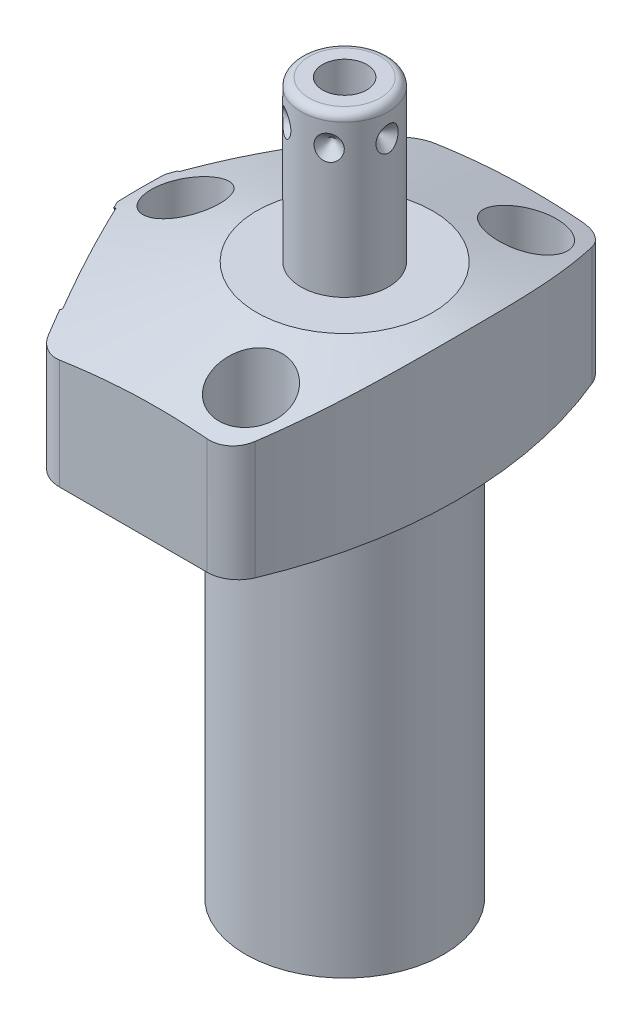
from build123d import *

# Parameters (mm, degrees)
CUT_EXTRUDE1_REACH = 21.05
CUT_EXTRUDE2_REACH = 21.05
S2D0002_OUTSIDE_W  = 78.27
S2D0002_OUTSIDE_H  = 69.906
CUT_EXTRUDE3_DEPTH = 26.035
FILLET1_R          = 3.9624
SKETCH17_R         = 10.4775
CUT_EXTRUDE4_DEPTH = 0.254
SKETCH18_R         = 10.4775
CUT_EXTRUDE5_DEPTH = 0.254
SKETCH19_R         = 5.5626
CUT_EXTRUDE6_DEPTH = 2.667
SKETCH12_R         = 4.8006
EXTRUDE1_DEPTH     = 1.651
EXTRUDE2_START     = -2.667
SKETCH13_R         = 4.8006
EXTRUDE2_DEPTH     = 2.667
CIRPATTERN1_COUNT  = 6
HOLE1_D            = 5.5626
HOLE1_DEPTH        = 19.05
HOLE1_CBORE_D      = 8.7122
HOLE1_CBORE_DEPTH  = 11.0998


with BuildPart() as part:
    # Sketch1 → Revolve1 (revolve)
    with BuildSketch(Plane(origin=(0, 0, 0), x_dir=(0, -1, 0), z_dir=(0, 0, 1)), mode=Mode.PRIVATE) as revolve1_sk:
        Polygon((0, 28.575), (-19.05, 28.575), (-19.05, 0), (50.8, 0), (50.8, 12.573), (0, 12.573), align=None)
    revolve(revolve1_sk.sketch.rotate(Axis((0, 22.5425, 0), (0, -1, 0)), 90), axis=Axis((0, 22.5425, 0), (0, -1, 0)))  # turned: the seam where the file's is

    # Sketch2 → Cut-Extrude1 (cut, up to next)
    with BuildSketch(Plane(origin=(0, 0, 0), x_dir=(0, 0, -1), z_dir=(0, -1, 0)), mode=Mode.PRIVATE) as cut_extrude1_sk1:
        with BuildLine():
            Line((23.8125, -15.795425564), (23.8125, 15.795425564))
            ThreePointArc((23.8125, 15.795425564), (28.575, 0), (23.8125, -15.795425564))
        make_face()
    cut_extrude1_tool1 = extrude(cut_extrude1_sk1.sketch, amount=-CUT_EXTRUDE1_REACH, mode=Mode.PRIVATE) & part.part
    add(cut_extrude1_tool1.solids().sort_by_distance((0, 0, -25.731798))[0], mode=Mode.SUBTRACT)
    # Sketch2 → Cut-Extrude1 (cut, up to next)
    with BuildSketch(Plane(origin=(0, 0, 0), x_dir=(0, 0, -1), z_dir=(0, -1, 0)), mode=Mode.PRIVATE) as cut_extrude1_sk2:
        with BuildLine():
            Line((-23.8125, 15.795425564), (-23.8125, -15.795425564))
            ThreePointArc((-23.8125, -15.795425564), (-28.575, 0), (-23.8125, 15.795425564))
        make_face()
    cut_extrude1_tool2 = extrude(cut_extrude1_sk2.sketch, amount=-CUT_EXTRUDE1_REACH, mode=Mode.PRIVATE) & part.part
    add(cut_extrude1_tool2.solids().sort_by_distance((0, 0, 25.731798))[0], mode=Mode.SUBTRACT)

    # Sketch3 → Cut-Extrude2 (cut, up to next)
    with BuildSketch(Plane(origin=(0, 0, 0), x_dir=(-1, 0, 0), z_dir=(0, -1, 0)), mode=Mode.PRIVATE) as cut_extrude2_sk1:
        with BuildLine():
            Line((14.75388632, 23.8125), (27.415217161, 0))
            Line((27.415217161, 0), (14.75388632, -23.8125))
            Line((14.75388632, -23.8125), (15.795425564, -23.8125))
            ThreePointArc((15.795425564, -23.8125), (28.575, 0), (15.795425564, 23.8125))
            Line((15.795425564, 23.8125), (14.75388632, 23.8125))
        make_face()
    cut_extrude2_tool1 = extrude(cut_extrude2_sk1.sketch, amount=-CUT_EXTRUDE2_REACH, mode=Mode.PRIVATE) & part.part
    add(cut_extrude2_tool1.solids().sort_by_distance((-15.274656, 0, -23.3166))[0], mode=Mode.SUBTRACT)

    # S2D0002 outside → Cut-Extrude3 (cut)
    with BuildSketch(Plane(origin=(0, 0, 0), x_dir=(-1, 0, 0), z_dir=(0, -1, 0))):
        with Locations((-0.58, 0)):
            Rectangle(S2D0002_OUTSIDE_W, S2D0002_OUTSIDE_H)
        with BuildLine():
            Line((25.8064, 53.379071452), (25.8064, -53.379071452))
            ThreePointArc((25.8064, -53.379071452), (-14.3002, 0), (25.8064, 53.379071452))
        make_face(mode=Mode.SUBTRACT)
    extrude(amount=-CUT_EXTRUDE3_DEPTH, mode=Mode.SUBTRACT)

    # Fillet1
    fillet1_edges = [part.edges().sort_by_distance(p)[0] for p in [
        (-14.75388632, 9.525, 23.8125),
        (-14.75388632, 9.525, -23.8125),
        (8.940213818, 9.525, 23.8125),
        (8.940213818, 9.525, -23.8125),
    ]]
    fillet(fillet1_edges, radius=FILLET1_R)

    # Sketch5 → Cut-Revolve1 (revolve, cut)
    with BuildSketch(Plane.XY, mode=Mode.PRIVATE) as cut_revolve1_sk:
        Polygon((-11.176, 19.05), (-44.45, 8.238622028), (-44.45, 19.05), align=None)
    revolve(cut_revolve1_sk.sketch.rotate(Axis((0, 5.998428823, 0), (0, 1, 0)), 90), axis=Axis((0, 5.998428823, 0), (0, 1, 0)), mode=Mode.SUBTRACT)  # turned: the seam where the file's is

    # Sketch6 → Cut-Revolve2 (revolve, cut)
    with BuildSketch(Plane(origin=(-21.148537334, 7.9502, -11.244876766), x_dir=(0.469471563, 0, -0.882947593), z_dir=(0, 1, 0))):
        Polygon((0, 0), (4.5466, 0), (4.106586662, -2.0701), (3.4544, -2.722286662), (3.4544, -12.192), (0, -12.192), align=None)
    revolve(axis=Axis((-9.845395429, 7.9502, -5.234889608), (-0.882947593, 0, -0.469471563)), mode=Mode.SUBTRACT)

    # Sketch7 → Cut-Revolve3 (revolve, cut)
    with BuildSketch(Plane(origin=(-21.148537334, 7.9502, 11.244876766), x_dir=(-0.469471563, 0, -0.882947593), z_dir=(0, 1, 0))):
        Polygon((0, 0), (4.5466, 0), (4.106586662, -2.0701), (3.4544, -2.722286662), (3.4544, -12.192), (0, -12.192), align=None)
    revolve(axis=Axis((-9.845395429, 7.9502, 5.234889608), (-0.882947593, 0, 0.469471563)), mode=Mode.SUBTRACT)

    # Sketch17 → Cut-Extrude4 (cut)
    with BuildSketch(Plane(origin=(-21.372806022, 0, 11.364122543), x_dir=(0.469471563, 0, 0.882947593), z_dir=(-0.882947593, 0, 0.469471563))):
        with Locations((0, 7.9502)):
            Circle(SKETCH17_R)
    extrude(amount=-CUT_EXTRUDE4_DEPTH, mode=Mode.SUBTRACT)

    # Sketch18 → Cut-Extrude5 (cut)
    with BuildSketch(Plane(origin=(-21.372806022, 0, -11.364122543), x_dir=(-0.469471563, 0, 0.882947593), z_dir=(-0.882947593, 0, -0.469471563))):
        with Locations((0, 7.9502)):
            Circle(SKETCH18_R)
    extrude(amount=-CUT_EXTRUDE5_DEPTH, mode=Mode.SUBTRACT)

    # Sketch8 → Cut-Revolve4 (revolve, cut)
    with BuildSketch(Plane(origin=(-11.1252, 2.667, -15.875), x_dir=(-1, 0, 0), z_dir=(0, 0, 1)), mode=Mode.PRIVATE) as cut_revolve4_sk:
        Polygon((0, 0), (4.5466, 0), (4.106586662, -2.0701), (3.4544, -2.722286662), (3.4544, -11.684), (0, -11.684), align=None)
    revolve(cut_revolve4_sk.sketch.rotate(Axis((-11.1252, 14.9352, -15.875), (0, -1, 0)), 270), axis=Axis((-11.1252, 14.9352, -15.875), (0, -1, 0)), mode=Mode.SUBTRACT)  # turned: the seam where the file's is

    # Sketch9 → Cut-Revolve5 (revolve, cut)
    with BuildSketch(Plane(origin=(-11.1252, 2.667, 15.875), x_dir=(-1, 0, 0), z_dir=(0, 0, 1)), mode=Mode.PRIVATE) as cut_revolve5_sk:
        Polygon((0, 0), (4.5466, 0), (4.106586662, -2.0701), (3.4544, -2.722286662), (3.4544, -11.684), (0, -11.684), align=None)
    revolve(cut_revolve5_sk.sketch.rotate(Axis((-11.1252, 14.9352, 15.875), (0, -1, 0)), 270), axis=Axis((-11.1252, 14.9352, 15.875), (0, -1, 0)), mode=Mode.SUBTRACT)  # turned: the seam where the file's is

    # Sketch10 → Revolve2 (revolve)
    with BuildSketch(Plane(origin=(0, 0, 0), x_dir=(0, 0, -1), z_dir=(1, 0, 0)), mode=Mode.PRIVATE) as revolve2_sk:
        with BuildLine():
            Line((0, 19.05), (-5.55625, 19.05))
            Line((-5.55625, 19.05), (-5.55625, 38.3032))
            ThreePointArc((-5.55625, 38.3032), (-5.25867049, 39.02162049), (-4.54025, 39.3192))
            Line((-4.54025, 39.3192), (0, 39.3192))
            Line((0, 39.3192), (0, 19.05))
        make_face()
    revolve(revolve2_sk.sketch.rotate(Axis((0, 18.03654, 0), (0, 1, 0)), 180), axis=Axis((0, 18.03654, 0), (0, 1, 0)))  # turned: the seam where the file's is

    # Sketch19 → Cut-Extrude6 (cut)
    with BuildSketch(Plane.XZ):
        with Locations(Location((-11.1252, -15.875, 0), (0, 0, 270))):  # turned: the seam where the file's is
            Circle(SKETCH19_R)
        with Locations(Location((-11.1252, 15.875, 0), (0, 0, 270))):  # turned: the seam where the file's is
            Circle(SKETCH19_R)
    extrude(amount=-CUT_EXTRUDE6_DEPTH, mode=Mode.SUBTRACT)

    # S2D0001 → Cut-Revolve6 (revolve, cut)
    with BuildSketch(Plane(origin=(2.8067, 39.3192, 0), x_dir=(1, 0, 0), z_dir=(0, 0, 1)), mode=Mode.PRIVATE) as cut_revolve6_sk:
        Polygon((0, 0), (0, -10.16), (-2.8067, -11.846435499), (-2.8067, 0), align=None)
    revolve(cut_revolve6_sk.sketch.rotate(Axis((0, 21.752471385, 0), (0, 1, 0)), 90), axis=Axis((0, 21.752471385, 0), (0, 1, 0)), mode=Mode.SUBTRACT)  # turned: the seam where the file's is

    # Sketch12 → Extrude1 (add)
    with BuildSketch(Plane(origin=(-21.148537334, 0, -11.244876766), x_dir=(0.469471563, 0, -0.882947593), z_dir=(0.882947593, 0, 0.469471563))):
        with Locations((0, 7.9502)):
            Circle(SKETCH12_R)
    extrude(amount=-EXTRUDE1_DEPTH)

    # Sketch13 → Extrude2 (add)
    with BuildSketch(Plane.XZ.offset(EXTRUDE2_START)):
        with Locations(Location((-11.1252, -15.875, 0), (0, 0, 270))):  # turned: the seam where the file's is
            Circle(SKETCH13_R)
    extrude(amount=EXTRUDE2_DEPTH)

    # Sketch14 → Revolve3 (revolve)
    with BuildSketch(Plane(origin=(-11.1252, 0, 15.875), x_dir=(0, 0, -1), z_dir=(1, 0, 0))):
        with BuildLine():
            Line((5.461, 2.667), (5.461, 0.9398))
            Line((5.461, 0.9398), (5.301559456, 0.9398))
            ThreePointArc((5.301559456, 0.9398), (4.572, -0.4572), (3.842440544, 0.9398))
            Line((3.842440544, 0.9398), (3.175, 0.9398))
            ThreePointArc((3.175, 0.9398), (2.815789755, 0.791010245), (2.667, 0.4318))
            Line((2.667, 0.4318), (2.667, 0.127))
            Line((2.667, 0.127), (1.5875, 0.127))
            Line((1.5875, 0.127), (1.5875, 10.6172))
            Line((1.5875, 10.6172), (3.2512, 10.6172))
            Line((3.2512, 10.6172), (3.2512, 2.667))
            Line((3.2512, 2.667), (5.461, 2.667))
        make_face()
    revolve(axis=Axis((-11.1252, -1.01092, 15.875), (0, 1, 0)))

    # Sketch15 → Cut-Revolve7 (revolve, cut)
    with BuildSketch(Plane(origin=(-5.55625, 35.3568, 0), x_dir=(0, 1, 0), z_dir=(0, 0, 1)), mode=Mode.PRIVATE) as cut_revolve7_sk:
        Polygon((0, 0), (1.5875, 0), (0, -1.5875), align=None)
    cut_revolve7 = revolve(cut_revolve7_sk.sketch.rotate(Axis((-1.854476352, 35.3568, 0), (-1, 0, 0)), 270), axis=Axis((-1.854476352, 35.3568, 0), (-1, 0, 0)), mode=Mode.SUBTRACT)  # turned: the seam where the file's is

    # CirPattern1: Cut-Revolve7 ×6 about axis
    cirpattern1_axis = Axis((0, 18.03654, 0), (0, -1, 0))
    for i in range(1, CIRPATTERN1_COUNT):
        add(cut_revolve7.rotate(cirpattern1_axis, i * 360 / CIRPATTERN1_COUNT), mode=Mode.SUBTRACT)

    # Hole1
    with Locations(Plane(origin=(0, 19.05, 0), x_dir=(-1, 0, 0), z_dir=(0, 1, 0))):
        with Locations((-5.5626, -17.4498), (20.193, 0), (-5.5626, 17.4498)):
            CounterBoreHole(HOLE1_D / 2, HOLE1_CBORE_D / 2, HOLE1_CBORE_DEPTH, depth=HOLE1_DEPTH)


solid = part.part
